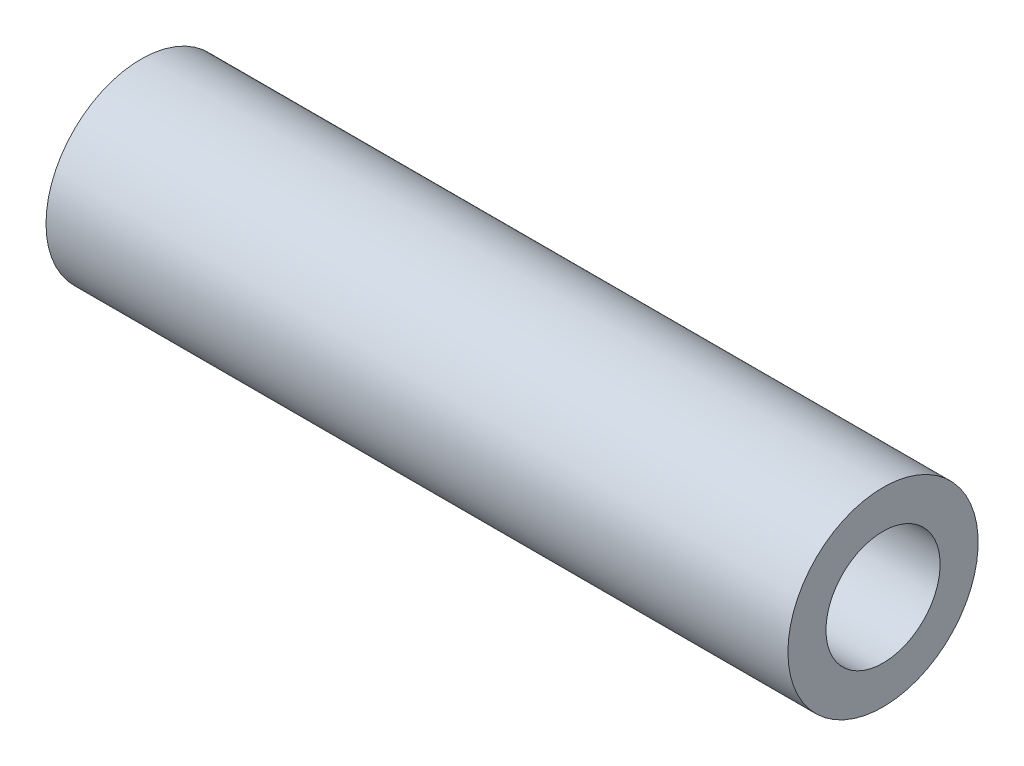
from build123d import *

# Parameters (mm, degrees)
SKETCH1_W = 165.1
SKETCH1_H = 8.466666667


with BuildPart() as part:
    # Sketch1 → Revolve1 (revolve)
    with BuildSketch(Plane.XY):
        with Locations((82.55, 16.933333334)):
            Rectangle(SKETCH1_W, SKETCH1_H)
    revolve(axis=Axis((0, 0, 0), (1, 0, 0)))


solid = part.part
